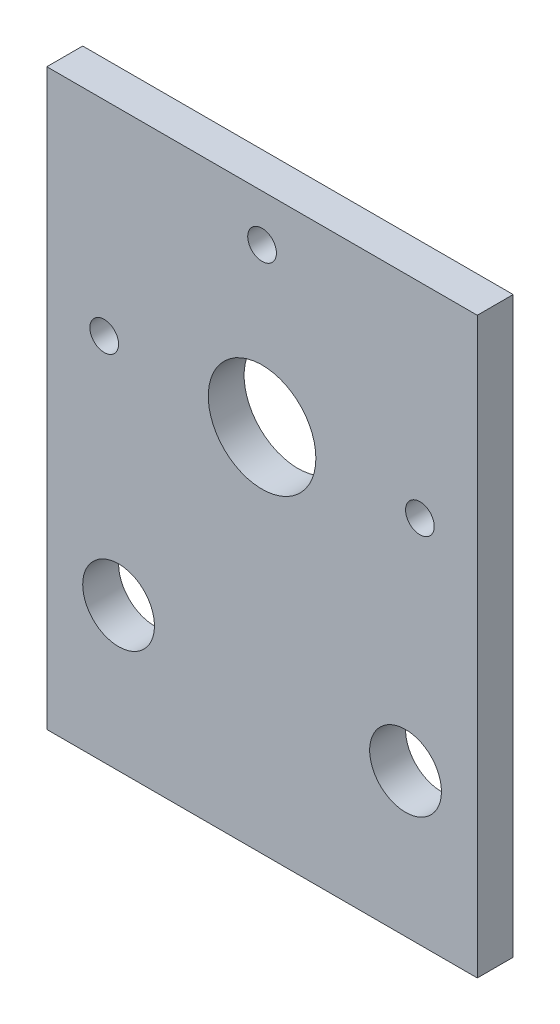
from build123d import *

# Parameters (mm, degrees)
SKETCH1_W           = 60
SKETCH1_H           = 80
SKETCH1_R           = 7.5
SKETCH1_R_2         = 5
SKETCH1_R_3         = 2
BOSS_EXTRUDE1_DEPTH = 5


with BuildPart() as part:
    # Sketch1 → Boss-Extrude1 (new body)
    with BuildSketch(Plane.XY):
        Rectangle(SKETCH1_W, SKETCH1_H)
        with Locations((0, 11.5)):
            Circle(SKETCH1_R, mode=Mode.SUBTRACT)
        with Locations((20, -20)):
            Circle(SKETCH1_R_2, mode=Mode.SUBTRACT)
        with Locations((0, 33.5)):
            Circle(SKETCH1_R_3, mode=Mode.SUBTRACT)
        with Locations((-22, 11.5)):
            Circle(SKETCH1_R_3, mode=Mode.SUBTRACT)
        with Locations((-20, -20)):
            Circle(SKETCH1_R_2, mode=Mode.SUBTRACT)
        with Locations((22, 11.5)):
            Circle(SKETCH1_R_3, mode=Mode.SUBTRACT)
    extrude(amount=BOSS_EXTRUDE1_DEPTH)


solid = part.part
